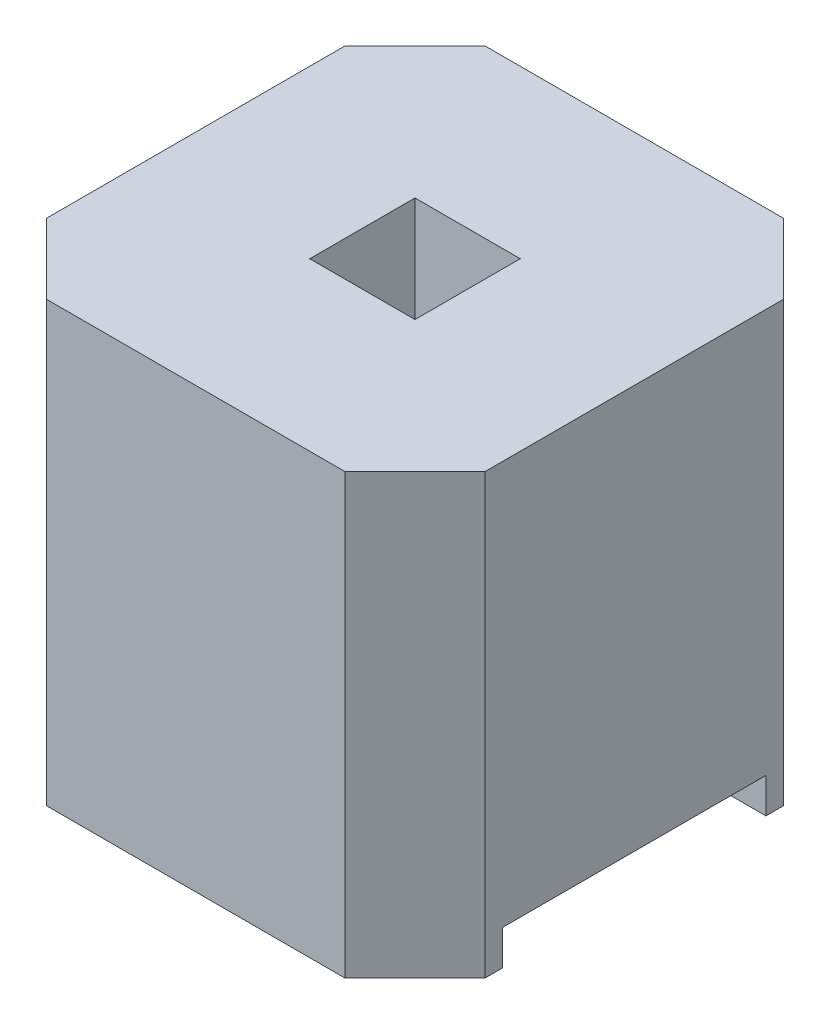
from build123d import *

# Parameters (mm, degrees)
ESQUISSE1_W             = 0.6
ESQUISSE1_H             = 0.6
BOSS_EXTRU_1_DEPTH      = 2.5
ESQUISSE2_W             = 1.5
ESQUISSE2_H             = 0.4
ENL_V_MAT_EXTRU_1_DEPTH = 3.5


with BuildPart() as part:
    # Esquisse1 → Boss.-Extru.1 (new body)
    with BuildSketch(Plane(origin=(0, 0, 0), x_dir=(1, 0, 0), z_dir=(0, 1, 0))):
        Polygon((-1.25, 0.85), (-0.85, 1.25), (0.85, 1.25), (1.25, 0.85), (1.25, -0.85), (0.85, -1.25), (-0.85, -1.25), (-1.25, -0.85), align=None)
        Rectangle(ESQUISSE1_W, ESQUISSE1_H, mode=Mode.SUBTRACT)
    extrude(amount=BOSS_EXTRU_1_DEPTH)

    # Esquisse2 → Enlèv. mat.-Extru.1 (cut, through all)
    with BuildSketch(Plane.ZY.offset(1.25)):
        Rectangle(ESQUISSE2_W, ESQUISSE2_H)
    extrude(amount=-ENL_V_MAT_EXTRU_1_DEPTH, mode=Mode.SUBTRACT)


solid = part.part
